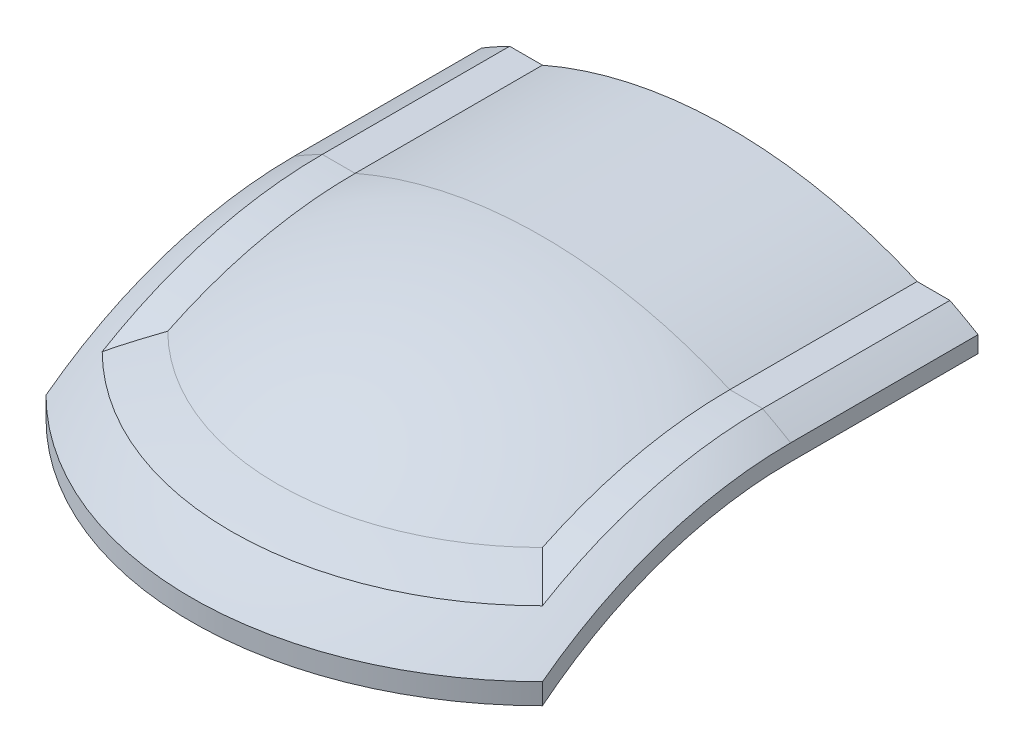
from build123d import *

# Parameters (mm, degrees)
EXTRUDE_1225_DEPTH     = 40
REVOLVE_1722_ANGLE     = 90
CUT_EXTRUDE_2087_DEPTH = 101
REVOLVE_2693_ANGLE     = 90


with BuildPart() as part:
    # 草图1 → Extrude 1225 (new body)
    with BuildSketch(Plane.XY):
        with BuildLine():
            Line((-50, 86.602540378), (-50, 83.120394609))
            ThreePointArc((-50, 83.120394609), (0, 97), (50, 83.120394609))
            Line((50, 83.120394609), (50, 86.602540378))
            ThreePointArc((50, 86.602540378), (45.070755856, 89.267166229), (40, 91.651513899))
            ThreePointArc((40, 91.651513899), (0, 100), (-40, 91.651513899))
            ThreePointArc((-40, 91.651513899), (-45.070755856, 89.267166229), (-50, 86.602540378))
        make_face()
        with BuildLine():
            ThreePointArc((40, 91.651513899), (45.070755856, 89.267166229), (50, 86.602540378))
            Line((50, 86.602540378), (50, 90.049986119))
            ThreePointArc((50, 90.049986119), (48.506610094, 90.863132112), (47, 91.651513899))
            Line((47, 91.651513899), (40, 91.651513899))
        make_face()
        with BuildLine():
            Line((50, 90.049986119), (50, 86.602540378))
            ThreePointArc((50, 86.602540378), (51.507887751, 85.714278271), (53, 84.799764151))
            Line((53, 84.799764151), (53, 88.317608663))
            ThreePointArc((53, 88.317608663), (51.507283785, 89.196410898), (50, 90.049986119))
        make_face()
        with BuildLine():
            Line((-50, 90.049986119), (-50, 86.602540378))
            ThreePointArc((-50, 86.602540378), (-45.070755856, 89.267166229), (-40, 91.651513899))
            Line((-40, 91.651513899), (-47, 91.651513899))
            ThreePointArc((-47, 91.651513899), (-48.506610094, 90.863132112), (-50, 90.049986119))
        make_face()
        with BuildLine():
            ThreePointArc((-53, 84.799764151), (-51.507887751, 85.714278271), (-50, 86.602540378))
            Line((-50, 86.602540378), (-50, 90.049986119))
            ThreePointArc((-50, 90.049986119), (-51.507283785, 89.196410898), (-53, 88.317608663))
            Line((-53, 88.317608663), (-53, 84.799764151))
        make_face()
    extrude(amount=-EXTRUDE_1225_DEPTH)

    # 草图5 → Revolve 1722 (revolve)
    with BuildSketch(Plane.XY):
        with BuildLine():
            Line((-50, 86.602540378), (-50, 83.120394609))
            ThreePointArc((-50, 83.120394609), (0, 97), (50, 83.120394609))
            Line((50, 83.120394609), (50, 86.602540378))
            ThreePointArc((50, 86.602540378), (51.507887751, 85.714278271), (53, 84.799764151))
            Line((53, 84.799764151), (53, 88.317608663))
            ThreePointArc((53, 88.317608663), (50.027779593, 90.034555971), (47, 91.651513899))
            Line((47, 91.651513899), (40, 91.651513899))
            ThreePointArc((40, 91.651513899), (0, 100), (-40, 91.651513899))
            Line((-40, 91.651513899), (-47, 91.651513899))
            ThreePointArc((-47, 91.651513899), (-50.027779593, 90.034555971), (-53, 88.317608663))
            Line((-53, 88.317608663), (-53, 84.799764151))
            ThreePointArc((-53, 84.799764151), (-51.507887751, 85.714278271), (-50, 86.602540378))
        make_face()
    revolve(axis=Axis((-50, 0, 0), (1, 0, 0)), revolution_arc=REVOLVE_1722_ANGLE)

    # 草图6 → Cut-Extrude 2087 (cut, through all)
    with BuildSketch(Plane(origin=(0, 0, 0), x_dir=(1, 0, 0), z_dir=(0, 1, 0))):
        with BuildLine():
            Line((0, 0), (-84.852813742, -84.852813742))
            ThreePointArc((-84.852813742, -84.852813742), (0, -120), (84.852813742, -84.852813742))
            Line((84.852813742, -84.852813742), (0, 0))
        make_face()
    extrude(amount=CUT_EXTRUDE_2087_DEPTH, mode=Mode.SUBTRACT)

    # 草图7 → Revolve 2693 (revolve)
    with BuildSketch(Plane(origin=(0, 0, 0), x_dir=(0.707106781, 0, -0.707106781), z_dir=(0.707106781, 0, 0.707106781))):
        with BuildLine():
            Line((-74.953318806, 70.647009845), (-74.953318806, 66.196676654))
            ThreePointArc((-74.953318806, 66.196676654), (-72.866961322, 68.486538441), (-70.710678119, 70.710678119))
            Line((-70.710678119, 70.710678119), (-70.710678119, 66.400301204))
            ThreePointArc((-70.710678119, 66.400301204), (-38.52382888, 89.021989466), (0, 97))
            Line((0, 97), (0, 100))
            ThreePointArc((0, 100), (-29.612402374, 95.514949749), (-56.568542495, 82.462112512))
            add(Edge.make_bspline(
                [(-56.568542495, 82.462112512), (-61.63437241, 80.724547186), (-66.468037432, 78.682907928)],
                knots=[5.164022421, 5.164022421, 5.164022421, 5.250846104, 5.250846104, 5.250846104], degree=2, weights=[1, 0.999057854, 1]))
            ThreePointArc((-66.468037432, 78.682907928), (-70.824740836, 74.785400216), (-74.953318806, 70.647009845))
        make_face()
    revolve(axis=Axis((0, 0, 0), (0, 1, 0)), revolution_arc=REVOLVE_2693_ANGLE)


solid = part.part
